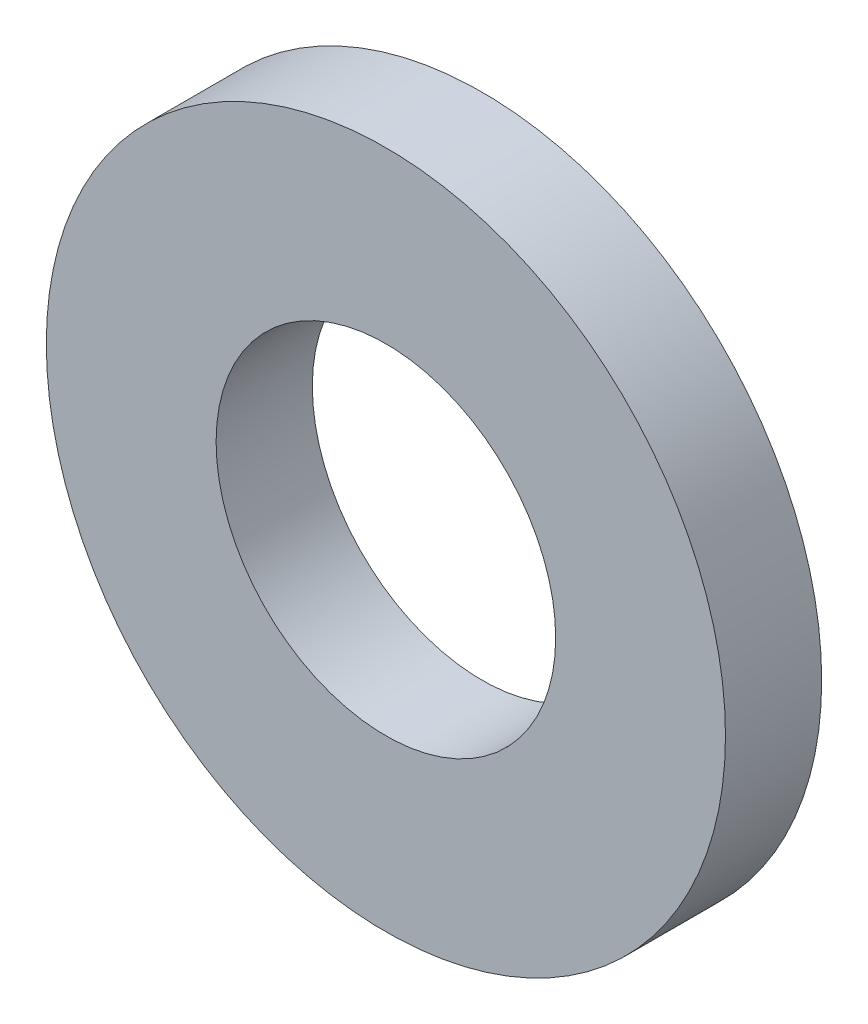
from build123d import *

# Parameters (mm, degrees)
SKETCH1_R           = 6
SKETCH1_R_2         = 3
BOSS_EXTRUDE1_DEPTH = 1.7


with BuildPart() as part:
    # Sketch1 → Boss-Extrude1 (new body)
    with BuildSketch(Plane.XY):
        Circle(SKETCH1_R)
        Circle(SKETCH1_R_2, mode=Mode.SUBTRACT)
    extrude(amount=BOSS_EXTRUDE1_DEPTH)


solid = part.part
